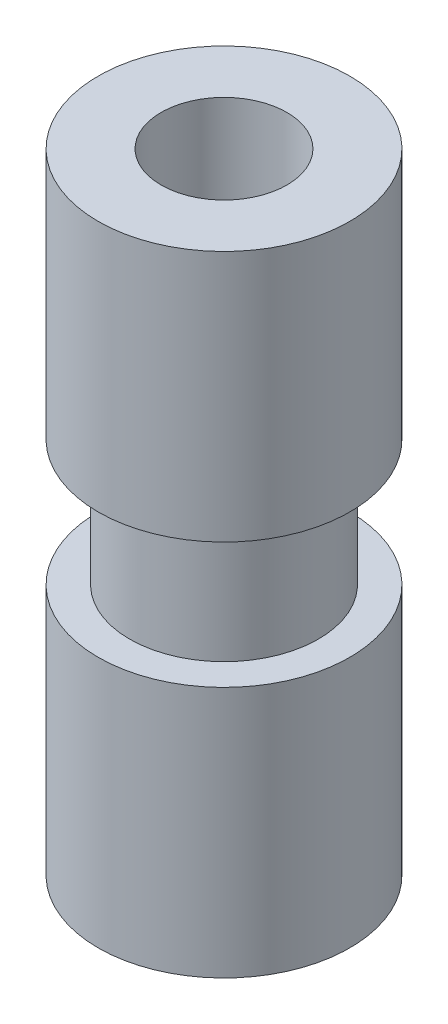
from build123d import *

# Parameters (mm, degrees)
SKETCH_1_R           = 2
SKETCH_1_R_2         = 1
EXTRUDE_1_DEPTH      = 6
EXTRUDE_1_DEPTH_BACK = 4
SKETCH_2_R           = 2
SKETCH_2_R_2         = 1.5
CUT_EXTRUDE_1_DEPTH  = 2


with BuildPart() as part:
    # 草图1 → 凸台-拉伸1 (new body, two sides)
    with BuildSketch(Plane(origin=(0, 0, 0), x_dir=(1, 0, 0), z_dir=(0, 1, 0))) as extrude_1_sk:
        Circle(SKETCH_1_R)
        Circle(SKETCH_1_R_2, mode=Mode.SUBTRACT)
    extrude(amount=EXTRUDE_1_DEPTH)
    extrude(extrude_1_sk.sketch, amount=-EXTRUDE_1_DEPTH_BACK)

    # 草图2 → 切除-拉伸1 (cut)
    with BuildSketch(Plane(origin=(0, 0, 0), x_dir=(1, 0, 0), z_dir=(0, 1, 0))):
        Circle(SKETCH_2_R)
        Circle(SKETCH_2_R_2, mode=Mode.SUBTRACT)
    extrude(amount=CUT_EXTRUDE_1_DEPTH, mode=Mode.SUBTRACT)


solid = part.part
